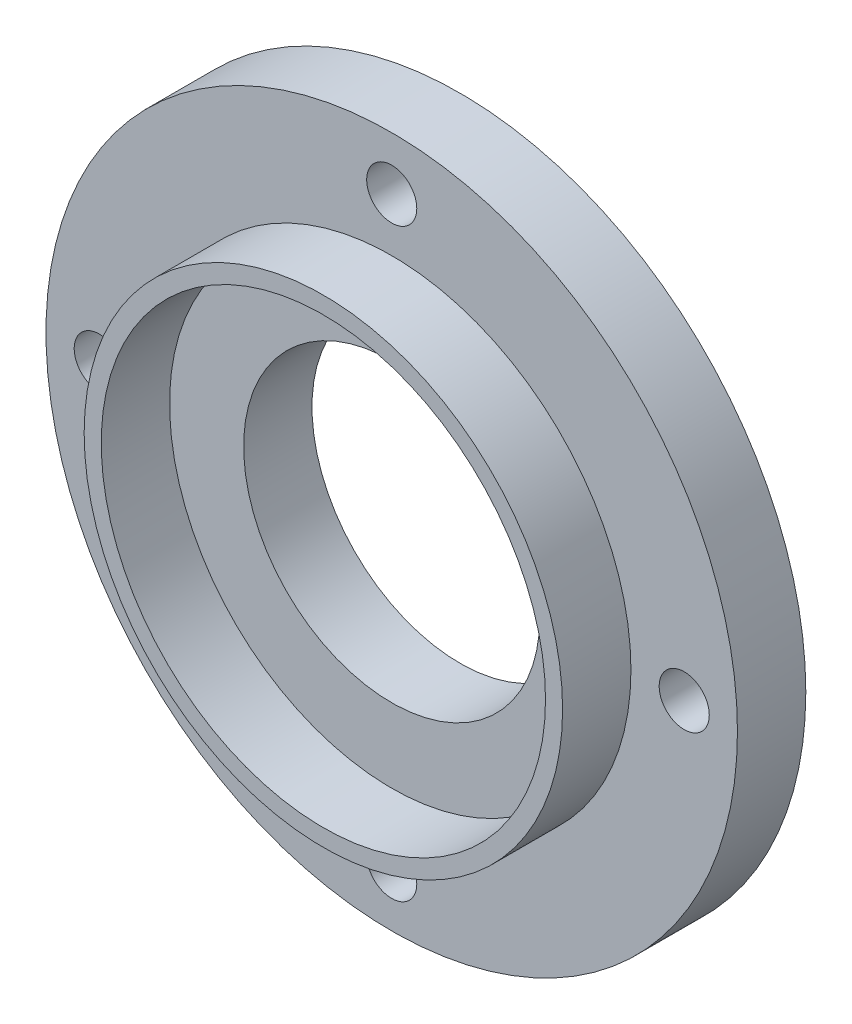
from build123d import *

# Parameters (mm, degrees)
SKETCH1_R                = 15.175
SKETCH1_R_2              = 6.5
BOSS_EXTRUDE1_DEPTH      = 3
SKETCH2_R                = 10.5
SKETCH2_R_2              = 9.75
BOSS_EXTRUDE2_DEPTH      = 3
M2_CLEARANCE_HOLE1_D     = 2.2
M2_CLEARANCE_HOLE1_DEPTH = 10
M2_CLEARANCE_HOLE1_TIP   = 0.660946681


with BuildPart() as part:
    # Sketch1 → Boss-Extrude1 (new body)
    with BuildSketch(Plane.XY):
        Circle(SKETCH1_R)
        Circle(SKETCH1_R_2, mode=Mode.SUBTRACT)
    extrude(amount=BOSS_EXTRUDE1_DEPTH)

    # Sketch2 → Boss-Extrude2 (add)
    with BuildSketch(Plane.XY.offset(3)):
        Circle(SKETCH2_R)
        Circle(SKETCH2_R_2, mode=Mode.SUBTRACT)
    extrude(amount=BOSS_EXTRUDE2_DEPTH)

    # M2 Clearance Hole1
    with Locations(Plane(origin=(0, 0, 0), x_dir=(-1, 0, 0), z_dir=(0, 0, -1))):
        with Locations((0, 12.8375), (12.8375, 0), (0, -12.8375), (-12.8375, 0)):
            Hole(M2_CLEARANCE_HOLE1_D / 2, depth=M2_CLEARANCE_HOLE1_DEPTH)
            with Locations((0, 0, -(M2_CLEARANCE_HOLE1_DEPTH + M2_CLEARANCE_HOLE1_TIP / 2))):  # 118° drill point
                Cone(0, M2_CLEARANCE_HOLE1_D / 2, M2_CLEARANCE_HOLE1_TIP, mode=Mode.SUBTRACT)


solid = part.part
